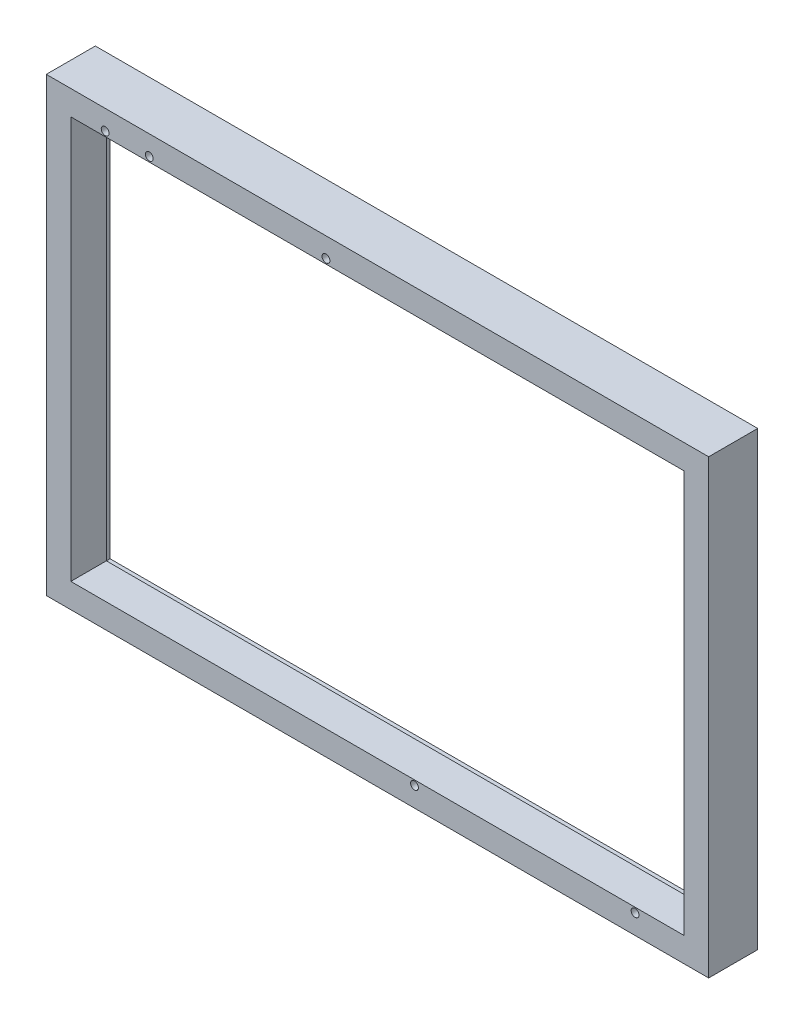
from build123d import *

# Parameters (mm, degrees)
SKETCH_1_W           = 135
SKETCH_1_H           = 92
SKETCH_1_R           = 0.8
SKETCH_1_W_2         = 125
SKETCH_1_H_2         = 82
EXTRUDE_1_DEPTH      = 10
EXTRUDE_1_DEPTH_BACK = 0.0001
SKETCH_4_W           = 129
SKETCH_4_H           = 86
CUT_EXTRUDE_1_DEPTH  = 2.75


with BuildPart() as part:
    # Эскиз1 → Бобышка-Вытянуть1 (new body, two sides)
    with BuildSketch(Plane.XY) as extrude_1_sk:
        with Locations((62.5, 41)):
            Rectangle(SKETCH_1_W, SKETCH_1_H)
        with Locations((7, 83)):
            Circle(SKETCH_1_R, mode=Mode.SUBTRACT)
        with Locations((115, -1)):
            Circle(SKETCH_1_R, mode=Mode.SUBTRACT)
        with Locations((16, 83)):
            Circle(SKETCH_1_R, mode=Mode.SUBTRACT)
        with Locations((52, 83)):
            Circle(SKETCH_1_R, mode=Mode.SUBTRACT)
        with Locations((70.05, -1)):
            Circle(SKETCH_1_R, mode=Mode.SUBTRACT)
        with Locations((62.5, 41)):
            Rectangle(SKETCH_1_W_2, SKETCH_1_H_2, mode=Mode.SUBTRACT)
    extrude(amount=EXTRUDE_1_DEPTH)
    extrude(extrude_1_sk.sketch, amount=-EXTRUDE_1_DEPTH_BACK)

    # Эскиз4 → Вырез-Вытянуть1 (cut)
    with BuildSketch(Plane(origin=(0, 0, -0.0001), x_dir=(-1, 0, 0), z_dir=(0, 0, -1))):
        with Locations((-62.5, 41)):
            Rectangle(SKETCH_4_W, SKETCH_4_H)
    extrude(amount=-CUT_EXTRUDE_1_DEPTH, mode=Mode.SUBTRACT)


solid = part.part
